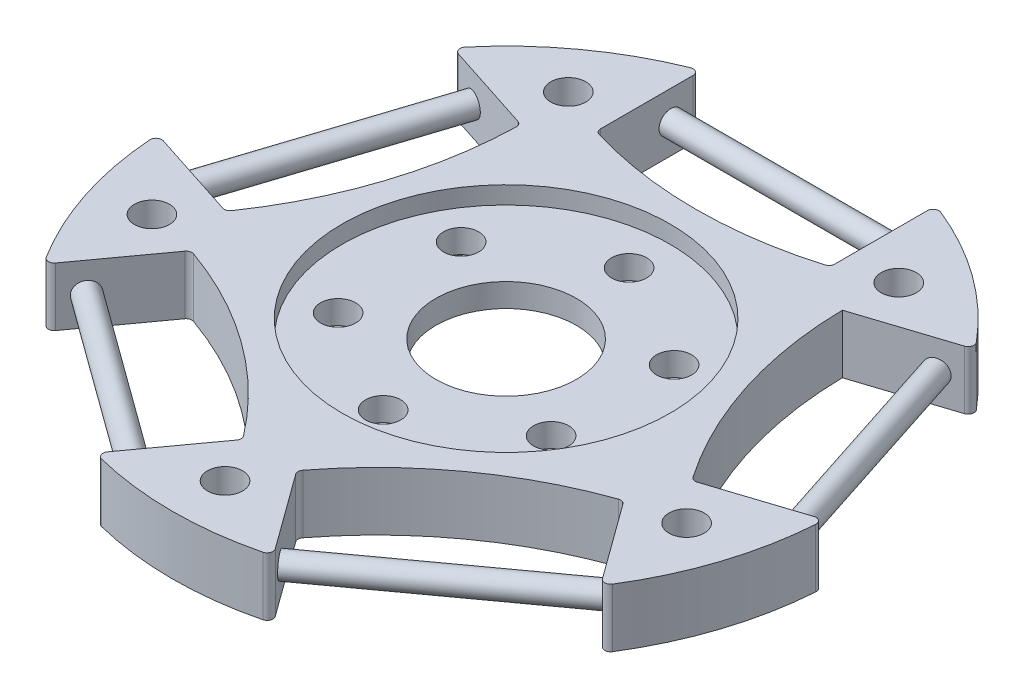
from build123d import *

# Parameters (mm, degrees)
SKETCH1_R           = 28.5
BOSS_EXTRUDE1_DEPTH = 5
CUT_EXTRUDE1_DEPTH  = 6
CIRPATTERN1_COUNT   = 5
SKETCH3_R           = 14
CUT_EXTRUDE2_DEPTH  = 1.5
SKETCH4_R           = 1.5
SKETCH4_R_2         = 6
CUT_EXTRUDE3_DEPTH  = 4.5
SKETCH5_R           = 1.5
CUT_EXTRUDE4_DEPTH  = 6
CIRPATTERN2_COUNT   = 5
FILLET1_R           = 0.5
SKETCH7_R           = 1
BOSS_EXTRUDE2_DEPTH = 20
CIRPATTERN3_COUNT   = 5
SCALE_1_SCALE       = 0.894736842


with BuildPart() as part:
    # Sketch1 → Boss-Extrude1 (new body)
    with BuildSketch(Plane(origin=(0, 0, 0), x_dir=(1, 0, 0), z_dir=(0, 1, 0))):
        Circle(SKETCH1_R)
    extrude(amount=BOSS_EXTRUDE1_DEPTH)

    # Sketch2 → Cut-Extrude1 (cut, through all)
    with BuildSketch(Plane(origin=(0, 5, 0), x_dir=(1, 0, 0), z_dir=(0, 1, 0))):
        with BuildLine():
            Line((10, 26.68801229), (10, 17.68801229))
            ThreePointArc((10, 17.68801229), (0, 16.180315356), (-10, 17.68801229))
            Line((-10, 17.68801229), (-10, 26.68801229))
            ThreePointArc((-10, 26.68801229), (0, 28.5), (10, 26.68801229))
        make_face()
    cut_extrude1 = extrude(amount=-CUT_EXTRUDE1_DEPTH, mode=Mode.SUBTRACT)

    # CirPattern1: Cut-Extrude1 ×5 about axis
    cirpattern1_axis = Axis((0, 0, 0), (0, 1, 0))
    for i in range(1, CIRPATTERN1_COUNT):
        add(cut_extrude1.rotate(cirpattern1_axis, i * 360 / CIRPATTERN1_COUNT), mode=Mode.SUBTRACT)

    # Sketch3 → Cut-Extrude2 (cut)
    with BuildSketch(Plane(origin=(0, 5, 0), x_dir=(1, 0, 0), z_dir=(0, 1, 0))):
        Circle(SKETCH3_R)
    cut_extrude2 = extrude(amount=-CUT_EXTRUDE2_DEPTH, mode=Mode.SUBTRACT)

    # Mirror1: Cut-Extrude2 across plane
    add(cut_extrude2.mirror(Plane.ZX.offset(2.5)), mode=Mode.SUBTRACT)

    # Sketch4 → Cut-Extrude3 (cut, through all)
    with BuildSketch(Plane(origin=(0, 3.5, 0), x_dir=(1, 0, 0), z_dir=(0, 1, 0))):
        with Locations((0, 10.5)):
            Circle(SKETCH4_R)
        with Locations((9.09326674, 5.25)):
            Circle(SKETCH4_R)
        with Locations((9.09326674, -5.25)):
            Circle(SKETCH4_R)
        with Locations((0, -10.5)):
            Circle(SKETCH4_R)
        with Locations((-9.09326674, -5.25)):
            Circle(SKETCH4_R)
        with Locations((-9.09326674, 5.25)):
            Circle(SKETCH4_R)
        Circle(SKETCH4_R_2)
    extrude(amount=-CUT_EXTRUDE3_DEPTH, mode=Mode.SUBTRACT)

    # Sketch5 → Cut-Extrude4 (cut, through all)
    with BuildSketch(Plane(origin=(0, 5, 0), x_dir=(1, 0, 0), z_dir=(0, 1, 0))):
        with Locations((0, -24)):
            Circle(SKETCH5_R)
    cut_extrude4 = extrude(amount=-CUT_EXTRUDE4_DEPTH, mode=Mode.SUBTRACT)

    # CirPattern2: Cut-Extrude4 ×5 about axis
    cirpattern2_axis = Axis((0, 0, 0), (0, 1, 0))
    for i in range(1, CIRPATTERN2_COUNT):
        add(cut_extrude4.rotate(cirpattern2_axis, i * 360 / CIRPATTERN2_COUNT), mode=Mode.SUBTRACT)

    # Fillet1
    fillet1_edges = [part.edges().sort_by_distance(p)[0] for p in [
        (-10, 2.5, -26.68801229),
        (10, 2.5, -26.68801229),
        (10, 2.5, -17.68801229),
        (-10, 2.5, -17.68801229),
        (22.291638052, 2.5, -17.757614507),
        (28.471977939, 2.5, 1.263515819),
        (19.912469293, 2.5, 4.044668769),
        (23.776989981, 2.5, 15.713202966),
        (7.596650093, 2.5, 27.468908012),
        (2.306582823, 2.5, 20.187755062),
        (18.48692271, 2.5, 8.432050017),
        (-7.596650093, 2.5, 27.468908012),
        (-23.776989981, 2.5, 15.713202966),
        (-18.48692271, 2.5, 8.432050017),
        (-2.306582823, 2.5, 20.187755062),
        (-28.471977939, 2.5, 1.263515819),
        (-22.291638052, 2.5, -17.757614507),
        (-13.732129405, 2.5, -14.976461557),
        (-19.912469293, 2.5, 4.044668769),
    ]]
    fillet(fillet1_edges, radius=FILLET1_R)

    # Sketch7 → Boss-Extrude2 (add)
    with BuildSketch(Plane(origin=(-8.090169944, 0, -5.877852523), x_dir=(0.587785252, 0, -0.809016994), z_dir=(0.809016994, 0, 0.587785252))):
        with Locations((-24.059120617, 2.5)):
            Circle(SKETCH7_R)
    boss_extrude2 = extrude(amount=BOSS_EXTRUDE2_DEPTH)

    # CirPattern3: Boss-Extrude2 ×5 about axis
    cirpattern3_axis = Axis((0, 3.5, 0), (0, 1, 0))
    for i in range(1, CIRPATTERN3_COUNT):
        add(boss_extrude2.rotate(cirpattern3_axis, i * 360 / CIRPATTERN3_COUNT))


with BuildPart() as part_1:
    # ｽｹｰﾙ1: scaled about (-0.000351369, 2.5, 0.00037965)
    add(part.part.scale(SCALE_1_SCALE).moved(Location((-3.6986e-05, 0.263157895, 3.9963e-05))))


solid = part_1.part
